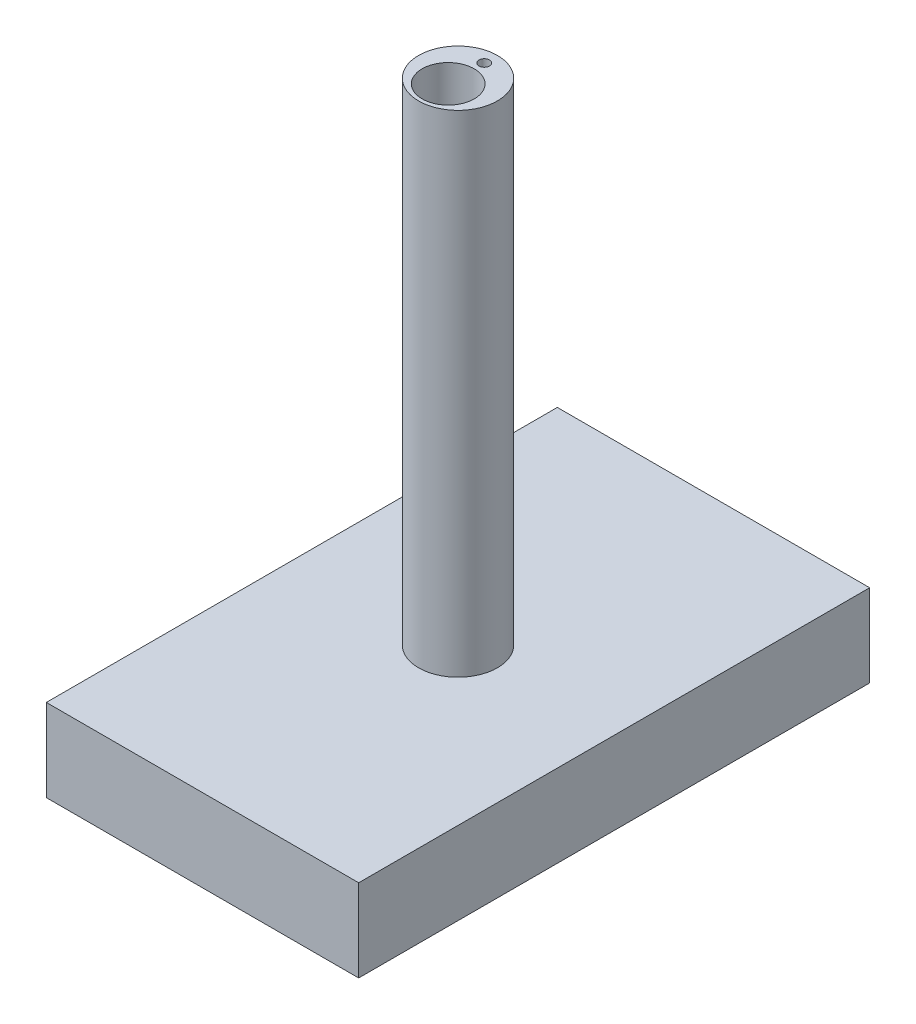
from build123d import *

# Parameters (mm, degrees)
SKETCH1_R           = 28.1
BOSS_EXTRUDE1_DEPTH = 350
SKETCH2_R           = 18.6
CUT_EXTRUDE1_DEPTH  = 58.8
SKETCH3_W           = 222.683092022
SKETCH3_H           = 364.2827524
BOSS_EXTRUDE2_DEPTH = 58.8
SKETCH4_W           = 207.917403516
SKETCH4_H           = 348.54429772
CUT_EXTRUDE2_DEPTH  = 48.8
SKETCH5_R           = 16.1
CUT_EXTRUDE3_DEPTH  = 350
SKETCH6_R           = 3.75
CUT_EXTRUDE5_DEPTH  = 400
BOSS_EXTRUDE3_DEPTH = 10
SKETCH8_R           = 10
CUT_EXTRUDE7_DEPTH  = 10
SKETCH9_W           = 37.5
SKETCH9_H           = 1
BOSS_EXTRUDE4_DEPTH = 1
SKETCH10_W          = 37.5
SKETCH10_H          = 1
BOSS_EXTRUDE5_DEPTH = 1
SKETCH11_W          = 77.5
SKETCH11_H          = 1
BOSS_EXTRUDE6_DEPTH = 1
SKETCH12_W          = 77.5
SKETCH12_H          = 1
BOSS_EXTRUDE7_DEPTH = 1


with BuildPart() as part:
    # Sketch1 → Boss-Extrude1 (new body)
    with BuildSketch(Plane(origin=(0, 0, 0), x_dir=(1, 0, 0), z_dir=(0, 1, 0))):
        Circle(SKETCH1_R)
    extrude(amount=BOSS_EXTRUDE1_DEPTH)

    # Sketch2 → Cut-Extrude1 (cut)
    with BuildSketch(Plane(origin=(0, 350, 0), x_dir=(1, 0, 0), z_dir=(0, 1, 0))):
        with Locations((0, -7)):
            Circle(SKETCH2_R)
    extrude(amount=-CUT_EXTRUDE1_DEPTH, mode=Mode.SUBTRACT)

    # Sketch3 → Boss-Extrude2 (add)
    with BuildSketch(Plane(origin=(0, 0, 0), x_dir=(-1, 0, 0), z_dir=(0, -1, 0))):
        Rectangle(SKETCH3_W, SKETCH3_H)
    extrude(amount=BOSS_EXTRUDE2_DEPTH)

    # Sketch4 → Cut-Extrude2 (cut)
    with BuildSketch(Plane(origin=(0, -58.8, 0), x_dir=(-1, 0, 0), z_dir=(0, -1, 0))):
        Rectangle(SKETCH4_W, SKETCH4_H)
    extrude(amount=-CUT_EXTRUDE2_DEPTH, mode=Mode.SUBTRACT)

    # Sketch5 → Cut-Extrude3 (cut)
    with BuildSketch(Plane(origin=(0, 291.2, 0), x_dir=(1, 0, 0), z_dir=(0, 1, 0))):
        with Locations((0, -7)):
            Circle(SKETCH5_R)
    extrude(amount=-CUT_EXTRUDE3_DEPTH, mode=Mode.SUBTRACT)

    # Sketch6 → Cut-Extrude5 (cut)
    with BuildSketch(Plane(origin=(0, 350, 0), x_dir=(1, 0, 0), z_dir=(0, 1, 0))):
        with Locations((0, 18.75)):
            Circle(SKETCH6_R)
    extrude(amount=-CUT_EXTRUDE5_DEPTH, mode=Mode.SUBTRACT)

    # Sketch7 → Boss-Extrude3 (add)
    with BuildSketch(Plane(origin=(0, -10, 0), x_dir=(-1, 0, 0), z_dir=(0, -1, 0))):
        Polygon((-33, 69.189999926), (-30.5, 69.189999926), (-30.5, 146.689999926), (30.5, 146.689999926), (30.5, 109.189999926), (33, 109.189999926), (33, 149.189999926), (-33, 149.189999926), align=None)
    extrude(amount=BOSS_EXTRUDE3_DEPTH)

    # Sketch8 → Cut-Extrude7 (cut)
    with BuildSketch(Plane(origin=(0, 0, -182.1413762), x_dir=(-1, 0, 0), z_dir=(0, 0, -1))):
        with Locations((-86.573671766, -25.011155335)):
            Circle(SKETCH8_R)
    extrude(amount=-CUT_EXTRUDE7_DEPTH, mode=Mode.SUBTRACT)

    # Sketch9 → Boss-Extrude4 (add)
    with BuildSketch(Plane(origin=(-30.5, 0, 0), x_dir=(0, 0, -1), z_dir=(1, 0, 0))):
        with Locations((127.939999926, -19.5)):
            Rectangle(SKETCH9_W, SKETCH9_H)
    extrude(amount=BOSS_EXTRUDE4_DEPTH)

    # Sketch10 → Boss-Extrude5 (add)
    with BuildSketch(Plane(origin=(-30.5, 0, 0), x_dir=(0, 0, -1), z_dir=(1, 0, 0))):
        with Locations((127.939999926, -14.5)):
            Rectangle(SKETCH10_W, SKETCH10_H)
    extrude(amount=BOSS_EXTRUDE5_DEPTH)

    # Sketch11 → Boss-Extrude6 (add)
    with BuildSketch(Plane.ZY.offset(-30.5)):
        with Locations((-107.939999926, -19.5)):
            Rectangle(SKETCH11_W, SKETCH11_H)
    extrude(amount=BOSS_EXTRUDE6_DEPTH)

    # Sketch12 → Boss-Extrude7 (add)
    with BuildSketch(Plane.ZY.offset(-30.5)):
        with Locations((-107.939999926, -14.5)):
            Rectangle(SKETCH12_W, SKETCH12_H)
    extrude(amount=BOSS_EXTRUDE7_DEPTH)


solid = part.part
